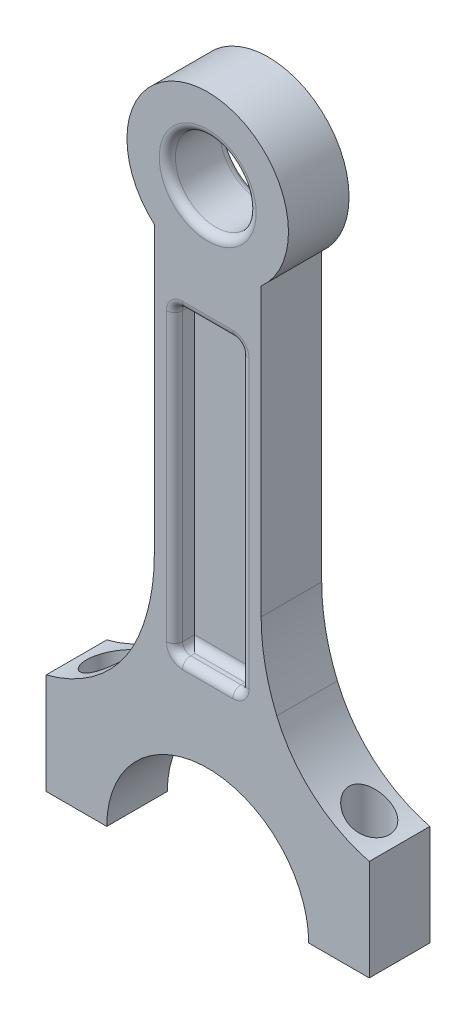
from build123d import *

# Parameters (mm, degrees)
BOSS_EXTRUDE1_DEPTH = 7.5
SKETCH2_R           = 10
CUT_EXTRUDE1_DEPTH  = 8.5
SKETCH3_W           = 16.45751311
SKETCH3_H           = 74.99964242
CUT_EXTRUDE2_DEPTH  = 5
FILLET2_R           = 2
FILLET3_R           = 2
FILLET4_R           = 2
BOSS_EXTRUDE2_DEPTH = 15
SKETCH8_R           = 5
CUT_EXTRUDE3_DEPTH  = 171


with BuildPart() as part:
    # Sketch1 → Boss-Extrude1 (new body)
    with BuildSketch(Plane.XY):
        with BuildLine():
            Line((-13.228756555, -15), (-13.228756555, -85.952171431))
            ThreePointArc((-13.228756555, -85.952171431), (-17.096585846, -105.234879374), (-28.10166958, -121.534298414))
            ThreePointArc((-28.10166958, -121.534298414), (-36.905736568, -134.573833645), (-40, -150))
            Line((-40, -150), (-25, -150))
            ThreePointArc((-25, -150), (-17.67766953, -132.32233047), (0, -125))
            ThreePointArc((0, -125), (17.67766953, -132.32233047), (25, -150))
            Line((25, -150), (40, -150))
            ThreePointArc((40, -150), (36.905736568, -134.573833645), (28.10166958, -121.534298414))
            ThreePointArc((28.10166958, -121.534298414), (17.096585846, -105.234879374), (13.228756555, -85.952171431))
            Line((13.228756555, -85.952171431), (13.228756555, -15))
            ThreePointArc((13.228756555, -15), (0, 20), (-13.228756555, -15))
        make_face()
    extrude(amount=BOSS_EXTRUDE1_DEPTH)

    # Sketch2 → Cut-Extrude1 (cut, through all)
    with BuildSketch(Plane.XY.offset(7.5)):
        Circle(SKETCH2_R)
    extrude(amount=-CUT_EXTRUDE1_DEPTH, mode=Mode.SUBTRACT)

    # Sketch3 → Cut-Extrude2 (cut)
    with BuildSketch(Plane.XY.offset(7.5)):
        with Locations((0, -67.5)):
            Rectangle(SKETCH3_W, SKETCH3_H)
    extrude(amount=-CUT_EXTRUDE2_DEPTH, mode=Mode.SUBTRACT)

    # Fillet2
    fillet2_edges = [part.edges().sort_by_distance(p)[0] for p in [
        (8.228756555, -30.00017879, 5),
        (0, -104.99982121, 2.5),
        (8.228756555, -104.99982121, 5),
        (-8.228756555, -104.99982121, 5),
        (0, -30.00017879, 2.5),
        (-8.228756555, -30.00017879, 5),
        (8.228756555, -67.5, 7.5),
        (0, -30.00017879, 7.5),
        (-8.228756555, -67.5, 7.5),
        (0, -104.99982121, 7.5),
    ]]
    fillet(fillet2_edges, radius=FILLET2_R)

    # Mirror1: part across plane


with BuildPart() as part_1:
    add(part.part)
    add(part.part.mirror(Plane(origin=(-63.228756555, -85.952171431, 0), x_dir=(1, 0, 0), z_dir=(0, 0, 1))))

    # Fillet3
    fillet3_edges = [part_1.edges().sort_by_distance(p)[0] for p in [
        (-10, 0, 7.5),
    ]]
    fillet(fillet3_edges, radius=FILLET3_R)

    # Fillet4
    fillet4_edges = [part_1.edges().sort_by_distance(p)[0] for p in [
        (-10, 0, -7.5),
    ]]
    fillet(fillet4_edges, radius=FILLET4_R)

    # Sketch7 → Boss-Extrude2 (add)
    with BuildSketch(Plane.XY.offset(7.5)):
        with BuildLine():
            Line((-40, -150), (-40, -125))
            ThreePointArc((-40, -125), (-26.219237737, -117.816300802), (-17.096585846, -105.234879374))
            ThreePointArc((-17.096585846, -105.234879374), (-21.789831556, -113.931011558), (-28.10166958, -121.534298414))
            ThreePointArc((-28.10166958, -121.534298414), (-36.905736568, -134.573833645), (-40, -150))
        make_face()
        with BuildLine():
            Line((40, -150), (40, -125))
            ThreePointArc((40, -125), (26.219237737, -117.816300802), (17.096585846, -105.234879374))
            ThreePointArc((17.096585846, -105.234879374), (21.789831556, -113.931011558), (28.10166958, -121.534298414))
            ThreePointArc((28.10166958, -121.534298414), (36.905736568, -134.573833645), (40, -150))
        make_face()
    extrude(amount=-BOSS_EXTRUDE2_DEPTH)

    # Sketch8 → Cut-Extrude3 (cut, through all)
    with BuildSketch(Plane(origin=(0, -150, 0), x_dir=(-1, 0, 0), z_dir=(0, -1, 0))):
        with Locations((32.5, 0)):
            Circle(SKETCH8_R)
        with Locations((-32.5, 0)):
            Circle(SKETCH8_R)
    extrude(amount=-CUT_EXTRUDE3_DEPTH, mode=Mode.SUBTRACT)


solid = part_1.part
